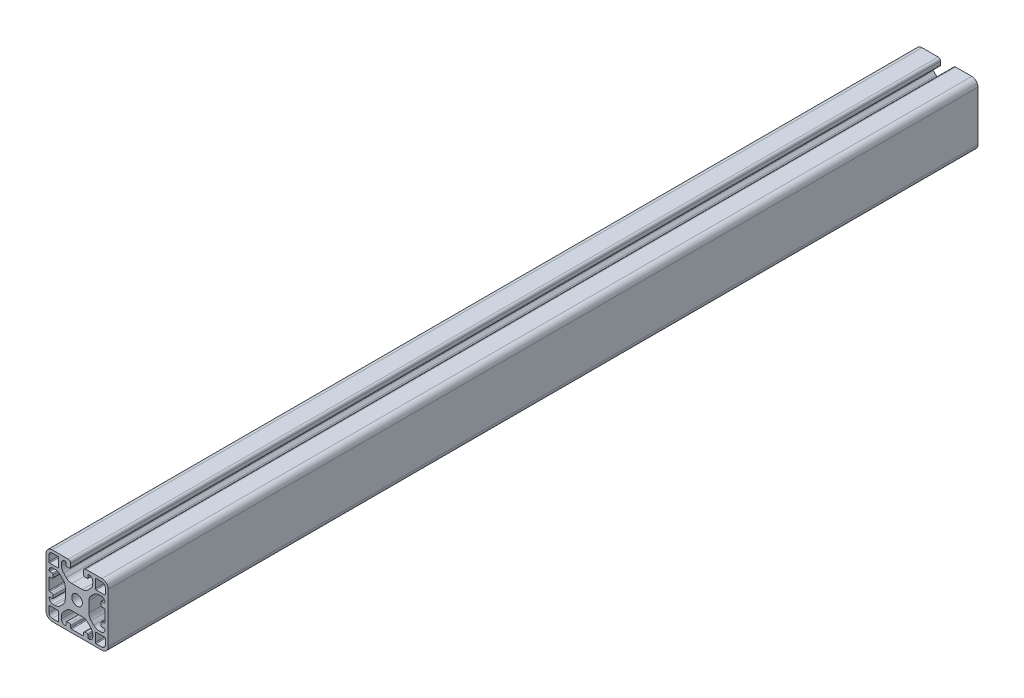
from build123d import *

# Parameters (mm, degrees)
SKIZZE1_R                       = 3.4
AUFSATZ_LINEAR_AUSTRAGEN1_DEPTH = 560
LINEARES_MUSTER1_COUNT          = 20
LINEARES_MUSTER1_PITCH          = 25


with BuildPart() as part:
    # Skizze1 → Aufsatz-Linear austragen1 (new body)
    with BuildSketch(Plane.XY.offset(560)):
        with BuildLine():
            Line((23.100000014, 35.850000004), (23.100000014, 37.500000007))
            ThreePointArc((23.100000014, 37.500000007), (23.246446625, 37.8535534), (23.600000018, 38.000000007))
            ThreePointArc((23.600000018, 38.000000007), (25.367766957, 37.267766953), (26.099999996, 35.500000007))
            Line((26.099999996, 35.500000007), (26.099999996, 34.292388137))
            ThreePointArc((26.099999996, 34.292388137), (25.719397659, 32.378970975), (24.635533902, 30.756854231))
            Line((24.635533902, 30.756854231), (22.943145774, 29.064466103))
            ThreePointArc((22.943145774, 29.064466103), (21.32102903, 27.980602346), (19.407611868, 27.600000008))
            Line((19.407611868, 27.600000008), (12.592388142, 27.600000008))
            ThreePointArc((12.592388142, 27.600000008), (10.678970981, 27.980602346), (9.056854237, 29.064466102))
            Line((9.056854237, 29.064466102), (7.36446608, 30.75685426))
            ThreePointArc((7.36446608, 30.75685426), (6.280602323, 32.378971004), (5.899999986, 34.292388165))
            Line((5.899999986, 34.292388165), (5.899999986, 35.500000003))
            ThreePointArc((5.899999986, 35.500000003), (6.632233037, 37.267766961), (8.399999999, 38.000000003))
            ThreePointArc((8.399999999, 38.000000003), (8.753553388, 37.853553393), (8.899999996, 37.500000003))
            Line((8.899999996, 37.500000003), (8.899999996, 35.850000004))
            ThreePointArc((8.899999996, 35.850000004), (9.046446605, 35.496446613), (9.399999996, 35.350000004))
            Line((9.399999996, 35.350000004), (10.899999944, 35.350000004))
            ThreePointArc((10.899999944, 35.350000004), (11.607106725, 35.642893223), (11.899999944, 36.350000004))
            Line((11.899999944, 36.350000004), (11.899999944, 38.500000016))
            ThreePointArc((11.899999944, 38.500000016), (11.460660115, 39.560660188), (10.399999943, 40.000000016))
            Line((10.399999943, 40.000000016), (4.8e-08, 40.000000016))
            ThreePointArc((4.8e-08, 40.000000016), (-2.828427121, 38.828427123), (-4.000000014, 35.999999954))
            Line((-4.000000014, 35.999999954), (-4.000000014, 4.000000069))
            ThreePointArc((-4.000000014, 4.000000069), (-2.828427124, 1.171572908), (3.7e-08, 1.8e-08))
            Line((3.7e-08, 1.8e-08), (31.999999922, 1.8e-08))
            ThreePointArc((31.999999922, 1.8e-08), (34.828427083, 1.171572908), (35.999999974, 4.000000069))
            Line((35.999999974, 4.000000069), (35.999999974, 35.999999953))
            ThreePointArc((35.999999974, 35.999999953), (34.82842708, 38.828427122), (31.99999991, 40.000000016))
            Line((31.99999991, 40.000000016), (21.599999961, 40.000000016))
            ThreePointArc((21.599999961, 40.000000016), (20.53933979, 39.560660188), (20.099999962, 38.500000017))
            Line((20.099999962, 38.500000017), (20.099999962, 36.350000004))
            ThreePointArc((20.099999962, 36.350000004), (20.392893181, 35.642893223), (21.099999962, 35.350000004))
            Line((21.099999962, 35.350000004), (22.600000014, 35.350000004))
            ThreePointArc((22.600000014, 35.350000004), (22.953553405, 35.496446613), (23.100000014, 35.850000004))
        make_face()
        with Locations((15.999999985, 20)):
            Circle(SKIZZE1_R, mode=Mode.SUBTRACT)
        with BuildLine():
            Line((4.8e-08, 38.200000033), (3.699999945, 38.200000033))
            ThreePointArc((3.699999945, 38.200000033), (4.053553343, 38.053553421), (4.199999956, 37.700000022))
            Line((4.199999956, 37.700000022), (4.199999956, 32.299999708))
            ThreePointArc((4.199999956, 32.299999708), (4.053553442, 31.946446549), (3.700000282, 31.800000035))
            Line((3.700000282, 31.800000035), (-1.70000008, 31.800000035))
            ThreePointArc((-1.70000008, 31.800000035), (-2.053553436, 31.94644663), (-2.200000031, 32.299999986))
            Line((-2.200000031, 32.299999986), (-2.200000031, 35.999999954))
            ThreePointArc((-2.200000031, 35.999999954), (-1.555634927, 37.555634929), (4.8e-08, 38.200000033))
        make_face(mode=Mode.SUBTRACT)
        with BuildLine():
            Line((-2.200000031, 4.000000069), (-2.200000031, 7.699999986))
            ThreePointArc((-2.200000031, 7.699999986), (-2.053553419, 8.053553385), (-1.70000002, 8.199999998))
            Line((-1.70000002, 8.199999998), (3.700000282, 8.199999998))
            ThreePointArc((3.700000282, 8.199999998), (4.053553442, 8.053553484), (4.199999956, 7.700000324))
            Line((4.199999956, 7.700000324), (4.199999956, 2.299999952))
            ThreePointArc((4.199999956, 2.299999952), (4.053553361, 1.946446596), (3.700000004, 1.800000001))
            Line((3.700000004, 1.800000001), (3.7e-08, 1.800000001))
            ThreePointArc((3.7e-08, 1.800000001), (-1.55563493, 2.444365102), (-2.200000031, 4.000000069))
        make_face(mode=Mode.SUBTRACT)
        with BuildLine():
            Line((31.999999922, 1.800000001), (28.300000004, 1.800000001))
            ThreePointArc((28.300000004, 1.800000001), (27.946446606, 1.946446613), (27.799999993, 2.300000012))
            Line((27.799999993, 2.300000012), (27.799999993, 7.700000324))
            ThreePointArc((27.799999993, 7.700000324), (27.946446507, 8.053553484), (28.299999667, 8.199999998))
            Line((28.299999667, 8.199999998), (33.700000039, 8.199999998))
            ThreePointArc((33.700000039, 8.199999998), (34.053553395, 8.053553402), (34.199999991, 7.700000046))
            Line((34.199999991, 7.700000046), (34.199999991, 4.000000069))
            ThreePointArc((34.199999991, 4.000000069), (33.555634889, 2.444365102), (31.999999922, 1.800000001))
        make_face(mode=Mode.SUBTRACT)
        with BuildLine():
            Line((34.199999991, 35.999999953), (34.199999991, 32.300000046))
            ThreePointArc((34.199999991, 32.300000046), (34.053553378, 31.946446648), (33.699999979, 31.800000035))
            Line((33.699999979, 31.800000035), (28.299999667, 31.800000035))
            ThreePointArc((28.299999667, 31.800000035), (27.946446507, 31.946446549), (27.799999993, 32.299999708))
            Line((27.799999993, 32.299999708), (27.799999993, 37.700000082))
            ThreePointArc((27.799999993, 37.700000082), (27.946446588, 38.053553438), (28.299999945, 38.200000033))
            Line((28.299999945, 38.200000033), (31.99999991, 38.200000033))
            ThreePointArc((31.99999991, 38.200000033), (33.555634886, 37.555634928), (34.199999991, 35.999999953))
        make_face(mode=Mode.SUBTRACT)
        with BuildLine():
            Line((12.592388143, 12.399999997), (19.407611847, 12.399999997))
            ThreePointArc((19.407611847, 12.399999997), (21.321029009, 12.01939766), (22.943145752, 10.935533904))
            Line((22.943145752, 10.935533904), (24.635533902, 9.243145754))
            ThreePointArc((24.635533902, 9.243145754), (25.719397659, 7.62102901), (26.099999996, 5.707611848))
            Line((26.099999996, 5.707611848), (26.099999996, 4.499999993))
            ThreePointArc((26.099999996, 4.499999993), (25.367766957, 2.732233048), (23.600000018, 1.999999995))
            ThreePointArc((23.600000018, 1.999999995), (23.246446625, 2.146446603), (23.100000014, 2.499999995))
            Line((23.100000014, 2.499999995), (23.100000014, 4.149999994))
            ThreePointArc((23.100000014, 4.149999994), (22.953553405, 4.503553383), (22.600000016, 4.649999992))
            Line((22.600000016, 4.649999992), (21.099999962, 4.649999992))
            ThreePointArc((21.099999962, 4.649999992), (20.392893181, 4.357106773), (20.099999962, 3.649999992))
            Line((20.099999962, 3.649999992), (20.099999962, 2.500000006))
            ThreePointArc((20.099999962, 2.500000006), (19.953553353, 2.146446616), (19.599999962, 2.000000006))
            Line((19.599999962, 2.000000006), (12.399999942, 2.000000006))
            ThreePointArc((12.399999942, 2.000000006), (12.046446553, 2.146446615), (11.899999944, 2.500000005))
            Line((11.899999944, 2.500000005), (11.899999944, 3.649999992))
            ThreePointArc((11.899999944, 3.649999992), (11.607106725, 4.357106773), (10.899999943, 4.649999992))
            Line((10.899999943, 4.649999992), (9.399999996, 4.649999992))
            ThreePointArc((9.399999996, 4.649999992), (9.046446606, 4.503553382), (8.899999996, 4.149999992))
            Line((8.899999996, 4.149999992), (8.899999996, 2.499999991))
            ThreePointArc((8.899999996, 2.499999991), (8.753553389, 2.146446604), (8.400000003, 1.999999994))
            ThreePointArc((8.400000003, 1.999999994), (6.632233039, 2.732233035), (5.899999986, 4.499999994))
            Line((5.899999986, 4.499999994), (5.899999986, 5.707611838))
            ThreePointArc((5.899999986, 5.707611838), (6.280602323, 7.621029001), (7.36446608, 9.243145746))
            Line((7.36446608, 9.243145746), (9.056854238, 10.935533903))
            ThreePointArc((9.056854238, 10.935533903), (10.678970982, 12.01939766), (12.592388143, 12.399999997))
        make_face(mode=Mode.SUBTRACT)
        with BuildLine():
            Line((-0.350000011, 15.899999977), (-1.500000012, 15.899999977))
            ThreePointArc((-1.500000012, 15.899999977), (-1.853553403, 16.046446586), (-2.000000012, 16.399999977))
            Line((-2.000000012, 16.399999977), (-2.000000012, 23.599999997))
            ThreePointArc((-2.000000012, 23.599999997), (-1.853553403, 23.953553386), (-1.500000014, 24.099999995))
            Line((-1.500000014, 24.099999995), (-0.350000011, 24.099999995))
            ThreePointArc((-0.350000011, 24.099999995), (0.35710677, 24.392893214), (0.649999989, 25.099999995))
            Line((0.649999989, 25.099999995), (0.649999989, 26.599999997))
            ThreePointArc((0.649999989, 26.599999997), (0.503553379, 26.953553388), (0.149999989, 27.099999997))
            Line((0.149999989, 27.099999997), (-1.500000012, 27.099999997))
            ThreePointArc((-1.500000012, 27.099999997), (-1.853553399, 27.246446604), (-2.000000009, 27.599999991))
            ThreePointArc((-2.000000009, 27.599999991), (-1.267766968, 29.367766955), (0.499999991, 30.100000008))
            Line((0.499999991, 30.100000008), (1.707611836, 30.100000008))
            ThreePointArc((1.707611836, 30.100000008), (3.621028998, 29.71939767), (5.243145743, 28.635533913))
            Line((5.243145743, 28.635533913), (6.935533893, 26.943145763))
            ThreePointArc((6.935533893, 26.943145763), (8.01939765, 25.321029019), (8.399999987, 23.407611857))
            Line((8.399999987, 23.407611857), (8.399999987, 16.592388128))
            ThreePointArc((8.399999987, 16.592388128), (8.01939765, 14.678970966), (6.935533894, 13.056854223))
            Line((6.935533894, 13.056854223), (5.243145736, 11.364466065))
            ThreePointArc((5.243145736, 11.364466065), (3.621028992, 10.280602309), (1.70761183, 9.899999971))
            Line((1.70761183, 9.899999971), (0.49999999, 9.899999971))
            ThreePointArc((0.49999999, 9.899999971), (-1.267766966, 10.632233022), (-2.000000008, 12.399999982))
            ThreePointArc((-2.000000008, 12.399999982), (-1.853553397, 12.753553371), (-1.500000008, 12.899999979))
            Line((-1.500000008, 12.899999979), (0.149999991, 12.899999979))
            ThreePointArc((0.149999991, 12.899999979), (0.50355338, 13.046446588), (0.649999989, 13.399999977))
            Line((0.649999989, 13.399999977), (0.649999989, 14.899999976))
            ThreePointArc((0.649999989, 14.899999976), (0.35710677, 15.607106758), (-0.350000011, 15.899999977))
        make_face(mode=Mode.SUBTRACT)
        with BuildLine():
            Line((23.599999999, 16.592388152), (23.599999999, 23.407611854))
            ThreePointArc((23.599999999, 23.407611854), (23.980602337, 25.321029015), (25.064466093, 26.943145759))
            Line((25.064466093, 26.943145759), (26.756854248, 28.635533914))
            ThreePointArc((26.756854248, 28.635533914), (28.378970992, 29.71939767), (30.292388154, 30.100000008))
            Line((30.292388154, 30.100000008), (31.49999999, 30.100000008))
            ThreePointArc((31.49999999, 30.100000008), (33.267766947, 29.367766956), (33.999999988, 27.599999994))
            ThreePointArc((33.999999988, 27.599999994), (33.853553377, 27.246446605), (33.499999988, 27.099999997))
            Line((33.499999988, 27.099999997), (31.849999989, 27.099999997))
            ThreePointArc((31.849999989, 27.099999997), (31.4964466, 26.953553388), (31.349999991, 26.6))
            Line((31.349999991, 26.6), (31.349999991, 25.099999995))
            ThreePointArc((31.349999991, 25.099999995), (31.64289321, 24.392893214), (32.349999991, 24.099999995))
            Line((32.349999991, 24.099999995), (33.499999986, 24.099999995))
            ThreePointArc((33.499999986, 24.099999995), (33.853553377, 23.953553386), (33.999999986, 23.599999995))
            Line((33.999999986, 23.599999995), (33.999999986, 16.399999975))
            ThreePointArc((33.999999986, 16.399999975), (33.853553377, 16.046446586), (33.499999988, 15.899999977))
            Line((33.499999988, 15.899999977), (32.349999991, 15.899999977))
            ThreePointArc((32.349999991, 15.899999977), (31.64289321, 15.607106758), (31.349999991, 14.899999977))
            Line((31.349999991, 14.899999977), (31.349999991, 13.39999998))
            ThreePointArc((31.349999991, 13.39999998), (31.496446601, 13.046446589), (31.849999991, 12.899999979))
            Line((31.849999991, 12.899999979), (33.499999992, 12.899999979))
            ThreePointArc((33.499999992, 12.899999979), (33.85355338, 12.753553372), (33.999999989, 12.399999985))
            ThreePointArc((33.999999989, 12.399999985), (33.267766947, 10.632233023), (31.499999989, 9.899999971))
            Line((31.499999989, 9.899999971), (30.292388181, 9.899999971))
            ThreePointArc((30.292388181, 9.899999971), (28.378971018, 10.280602309), (26.756854273, 11.364466066))
            Line((26.756854273, 11.364466066), (25.064466093, 13.056854246))
            ThreePointArc((25.064466093, 13.056854246), (23.980602337, 14.67897099), (23.599999999, 16.592388152))
        make_face(mode=Mode.SUBTRACT)
    extrude(amount=-AUFSATZ_LINEAR_AUSTRAGEN1_DEPTH)

    # Skizze3 → M3 Gewindebohrung1 (revolve, cut)
    with BuildSketch(Plane(origin=(15.999999979, 0, 500), x_dir=(0, 0, -1), z_dir=(1, 0, 0))):
        Polygon((0, 0), (0, 27.600000008), (1.525, 27.600000008), (1.25, 27.325000008), (1.25, 0), align=None)
    m3_gewindebohrung1 = revolve(axis=Axis((15.999999979, -6.35, 500), (0, 1, 0)), mode=Mode.SUBTRACT)

    # Lineares Muster1: M3 Gewindebohrung1 ×20
    with Locations(*[(0, 0, -i * LINEARES_MUSTER1_PITCH) for i in range(1, LINEARES_MUSTER1_COUNT)]):
        add(m3_gewindebohrung1, mode=Mode.SUBTRACT)


solid = part.part
